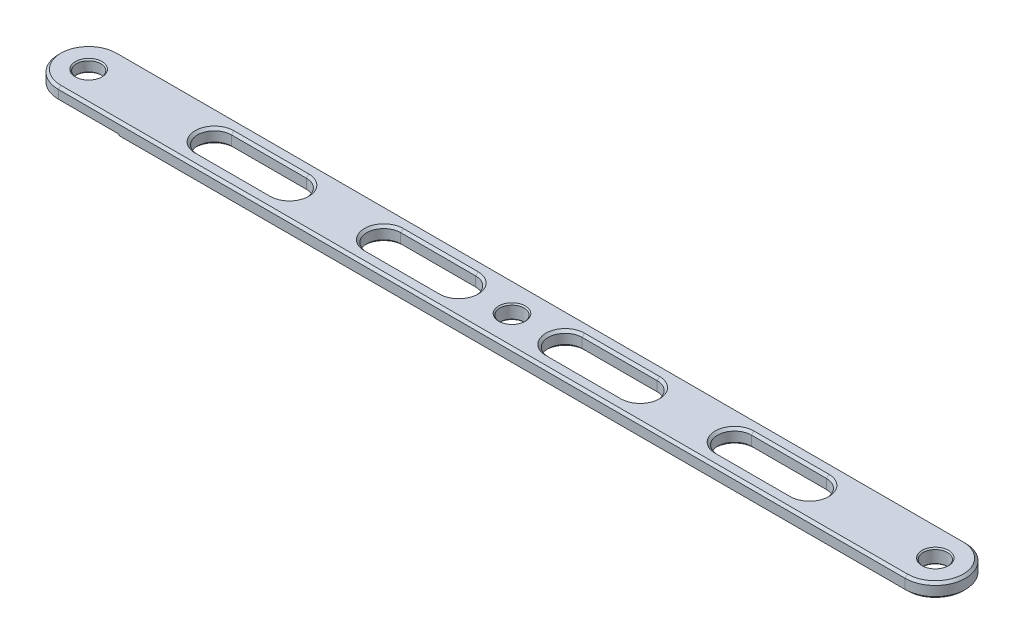
from build123d import *

# Parameters (mm, degrees)
ESQUISSE1_R             = 5
BOSS_EXTRU_1_DEPTH      = 6
ESQUISSE2_R             = 5
ENL_V_MAT_EXTRU_1_DEPTH = 1
CHANFREIN7_SIZE         = 0.5
CHANFREIN8_SIZE         = 1
CHANFREIN9_SIZE         = 1
CHANFREIN10_SIZE        = 1
CHANFREIN11_SIZE        = 0.5
CHANFREIN12_SIZE        = 0.5


with BuildPart() as part:
    # Esquisse1 → Boss.-Extru.1 (new body)
    with BuildSketch(Plane(origin=(0, 0, 0), x_dir=(1, 0, 0), z_dir=(0, 1, 0))):
        with BuildLine():
            Line((0, 12.5), (350, 12.5))
            ThreePointArc((350, 12.5), (362.5, 0), (350, -12.5))
            Line((350, -12.5), (0, -12.5))
            ThreePointArc((0, -12.5), (-12.5, 0), (0, 12.5))
        make_face()
        with Locations(Location((0, 0, 0), (0, 0, 270))):  # turned: the seam where the file's is
            Circle(ESQUISSE1_R, mode=Mode.SUBTRACT)
        with Locations(Location((350, 0, 0), (0, 0, 270))):  # turned: the seam where the file's is
            Circle(ESQUISSE1_R, mode=Mode.SUBTRACT)
        with Locations(Location((175, 0, 0), (0, 0, 270))):  # turned: the seam where the file's is
            Circle(ESQUISSE1_R, mode=Mode.SUBTRACT)
        with BuildLine():
            Line((52, 7), (83, 7))
            ThreePointArc((83, 7), (90, 0), (83, -7))
            Line((83, -7), (52, -7))
            ThreePointArc((52, -7), (45, 0), (52, 7))
        make_face(mode=Mode.SUBTRACT)
        with BuildLine():
            Line((122, 7), (153, 7))
            ThreePointArc((153, 7), (160, 0), (153, -7))
            Line((153, -7), (122, -7))
            ThreePointArc((122, -7), (115, 0), (122, 7))
        make_face(mode=Mode.SUBTRACT)
        with BuildLine():
            Line((197, 7), (228, 7))
            ThreePointArc((228, 7), (235, 0), (228, -7))
            Line((228, -7), (197, -7))
            ThreePointArc((197, -7), (190, 0), (197, 7))
        make_face(mode=Mode.SUBTRACT)
        with BuildLine():
            Line((267, 7), (298, 7))
            ThreePointArc((298, 7), (305, 0), (298, -7))
            Line((298, -7), (267, -7))
            ThreePointArc((267, -7), (260, 0), (267, 7))
        make_face(mode=Mode.SUBTRACT)
    extrude(amount=BOSS_EXTRU_1_DEPTH)

    # Esquisse2 → Enlèv. mat.-Extru.1 (cut)
    with BuildSketch(Plane.XZ):
        with BuildLine():
            Line((0, -12.5), (25, -12.5))
            Line((25, -12.5), (25, 12.5))
            Line((25, 12.5), (0, 12.5))
            ThreePointArc((0, 12.5), (-12.5, 0), (0, -12.5))
        make_face()
        with Locations(Location((0, 0, 0), (0, 0, 270))):  # turned: the seam where the file's is
            Circle(ESQUISSE2_R, mode=Mode.SUBTRACT)
    extrude(amount=-ENL_V_MAT_EXTRU_1_DEPTH, mode=Mode.SUBTRACT)

    # Chanfrein7
    chanfrein7_edges = [part.edges().sort_by_distance(p)[0] for p in [
        (-12.5, 1, 0),
        (12.5, 1, 12.5),
        (12.5, 1, -12.5),
    ]]
    chamfer(chanfrein7_edges, length=CHANFREIN7_SIZE)

    # Chanfrein8
    chanfrein8_edges = [part.edges().sort_by_distance(p)[0] for p in [
        (190, 0, 0),
        (212.5, 0, 7),
        (235, 0, 0),
        (212.5, 0, -7),
        (190, 6, 0),
        (212.5, 6, 7),
        (235, 6, 0),
        (212.5, 6, -7),
        (45, 0, 0),
        (67.5, 0, 7),
        (90, 0, 0),
        (67.5, 0, -7),
        (45, 6, 0),
        (67.5, 6, 7),
        (90, 6, 0),
        (67.5, 6, -7),
        (160, 0, 0),
        (137.5, 0, -7),
        (115, 0, 0),
        (137.5, 0, 7),
        (160, 6, 0),
        (137.5, 6, -7),
        (115, 6, 0),
        (137.5, 6, 7),
        (305, 0, 0),
        (282.5, 0, -7),
        (260, 0, 0),
        (282.5, 0, 7),
        (305, 6, 0),
        (282.5, 6, -7),
        (260, 6, 0),
        (282.5, 6, 7),
    ]]
    chamfer(chanfrein8_edges, length=CHANFREIN8_SIZE)

    # Chanfrein9
    chanfrein9_edges = [part.edges().sort_by_distance(p)[0] for p in [
        (187.5, 0, -12.5),
        (362.5, 0, 0),
        (187.5, 0, 12.5),
    ]]
    chamfer(chanfrein9_edges, length=CHANFREIN9_SIZE)

    # Chanfrein10
    chanfrein10_edges = [part.edges().sort_by_distance(p)[0] for p in [
        (362.5, 6, 0),
        (175, 6, -12.5),
        (-12.5, 6, 0),
        (175, 6, 12.5),
    ]]
    chamfer(chanfrein10_edges, length=CHANFREIN10_SIZE)

    # Chanfrein11
    chanfrein11_edges = [part.edges().sort_by_distance(p)[0] for p in [
        (175, 0, -5),
        (175, 6, -5),
    ]]
    chamfer(chanfrein11_edges, length=CHANFREIN11_SIZE)

    # Chanfrein12
    chanfrein12_edges = [part.edges().sort_by_distance(p)[0] for p in [
        (350, 0, -5),
        (350, 6, -5),
        (0, 6, -5),
        (0, 1, -5),
    ]]
    chamfer(chanfrein12_edges, length=CHANFREIN12_SIZE)


solid = part.part
